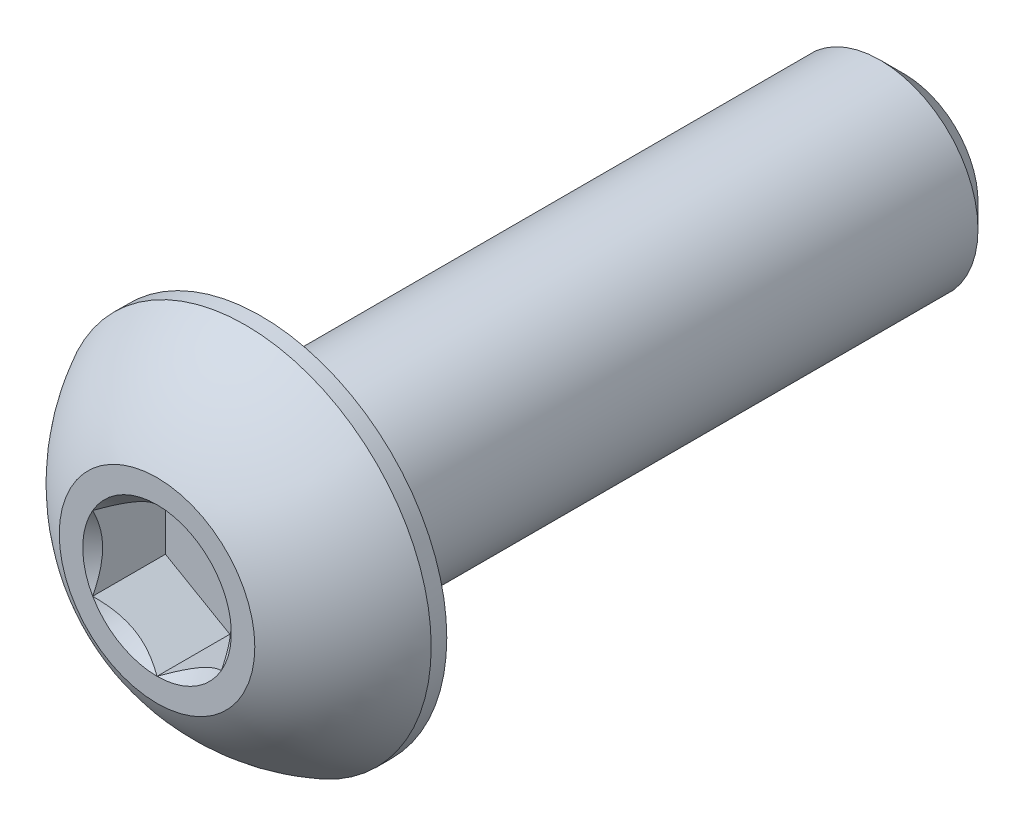
from build123d import *

# Parameters (mm, degrees)
SKETCH1_W          = 15.875
SKETCH1_H          = 2.413
CHAMFER1_SIZE      = 0.5953125
CUT_EXTRUDE2_DEPTH = 1.79578
SKETCH6_R          = 1.833087105
CUT_EXTRUDE3_DEPTH = 1.79578
CUT_EXTRUDE3_TAPER = 45


with BuildPart() as part:
    # Sketch1 → Revolve1 (revolve)
    with BuildSketch(Plane(origin=(0, 0, 0), x_dir=(0, 0, -1), z_dir=(1, 0, 0))):
        with Locations((10.5029, 1.2065)):
            Rectangle(SKETCH1_W, SKETCH1_H)
    revolve(axis=Axis((0, 0, -18.4404), (0, 0, 1)))

    # Chamfer1
    chamfer1_edges = [part.edges().sort_by_distance(p)[0] for p in [
        (0, -2.413, -18.4404),
    ]]
    chamfer(chamfer1_edges, length=CHAMFER1_SIZE)

    # Sketch7 → Revolve2 (revolve)
    with BuildSketch(Plane(origin=(0, 0, 0), x_dir=(0, 0, -1), z_dir=(1, 0, 0)), mode=Mode.PRIVATE) as revolve2_sk:
        with BuildLine():
            Line((2.18059, 4.5847), (2.5654, 4.5847))
            Line((2.5654, 4.5847), (2.5654, 0))
            Line((2.5654, 0), (0, 0))
            Line((0, 0), (0, 2.413))
            ThreePointArc((0, 2.413), (0.925030326, 3.664791196), (2.18059, 4.5847))
        make_face()
    revolve(revolve2_sk.sketch.rotate(Axis((0, 0, 0), (0, 0, -1)), 180), axis=Axis((0, 0, 0), (0, 0, -1)))

    # Sketch5 → Cut-Extrude2 (cut)
    with BuildSketch(Plane.XY):
        Polygon((1.5875, -0.916543552), (1.5875, 0.916543552), (0, 1.833087105), (-1.5875, 0.916543552), (-1.5875, -0.916543552), (0, -1.833087105), align=None)
    extrude(amount=-CUT_EXTRUDE2_DEPTH, mode=Mode.SUBTRACT)

    # Sketch6 → Cut-Extrude3 (cut)
    with BuildSketch(Plane.XY):
        Circle(SKETCH6_R)
    extrude(amount=-CUT_EXTRUDE3_DEPTH, taper=CUT_EXTRUDE3_TAPER, mode=Mode.SUBTRACT)


solid = part.part
